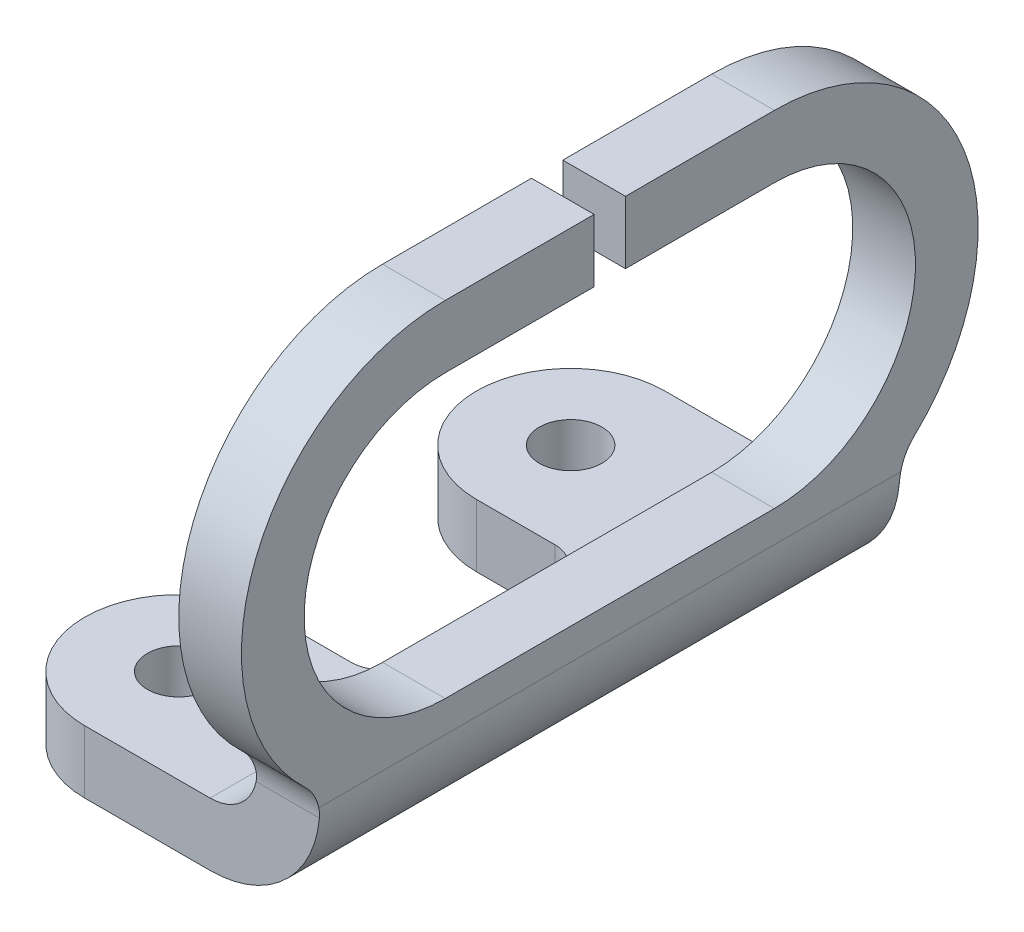
from build123d import *

# Parameters (mm, degrees)
SKETCH1_R           = 2
BOSS_EXTRUDE1_DEPTH = 4
SKETCH1_3_W         = 4
SKETCH1_3_H         = 56
BOSS_EXTRUDE2_DEPTH = 35
FILLET3_R           = 2
CUT_EXTRUDE2_DEPTH  = 10
SKETCH4_W           = 2
SKETCH4_H           = 8.349248205
CUT_EXTRUDE3_DEPTH  = 10
FILLET4_R           = 3
FILLET6_R           = 3
FILLET5_R           = 7


with BuildPart() as part:
    # Sketch1 → Boss-Extrude1 (new body)
    with BuildSketch(Plane(origin=(0, 0, 0), x_dir=(1, 0, 0), z_dir=(0, 1, 0))):
        with BuildLine():
            Line((33.647984737, 18.5), (22.647984737, 18.5))
            ThreePointArc((22.647984737, 18.5), (16.647984737, 12.5), (22.647984737, 6.5))
            Line((22.647984737, 6.5), (29.647984737, 6.5))
            Line((29.647984737, 6.5), (29.647984737, -6.5))
            Line((29.647984737, -6.5), (22.647984737, -6.5))
            ThreePointArc((22.647984737, -6.5), (16.647984737, -12.5), (22.647984737, -18.5))
            Line((22.647984737, -18.5), (33.647984737, -18.5))
            Line((33.647984737, -18.5), (33.647984737, 18.5))
        make_face()
        with Locations((22.647984737, 12.5)):
            Circle(SKETCH1_R, mode=Mode.SUBTRACT)
        with Locations((22.647984737, -12.5)):
            Circle(SKETCH1_R, mode=Mode.SUBTRACT)
    extrude(amount=BOSS_EXTRUDE1_DEPTH)

    # Sketch1_3 → Boss-Extrude2 (add)
    with BuildSketch(Plane(origin=(0, 0, 0), x_dir=(1, 0, 0), z_dir=(0, 1, 0))):
        with Locations((35.647984737, 0)):
            Rectangle(SKETCH1_3_W, SKETCH1_3_H)
    extrude(amount=BOSS_EXTRUDE2_DEPTH)

    # Fillet3
    fillet3_edges = [part.edges().sort_by_distance(p)[0] for p in [
        (29.647984737, 2, -6.5),
        (29.647984737, 2, 6.5),
    ]]
    fillet(fillet3_edges, radius=FILLET3_R)

    # Sketch3 → Cut-Extrude2 (cut)
    with BuildSketch(Plane(origin=(37.647984737, 0, 0), x_dir=(0, 0, -1), z_dir=(1, 0, 0))):
        with BuildLine():
            Line((-28, 0), (-18.5, 0))
            Line((-18.5, 0), (-18.5, 7.753049234))
            ThreePointArc((-18.5, 7.753049234), (-22.792484695, 22.230226947), (-10.5, 31))
            Line((-10.5, 31), (10.5, 31))
            ThreePointArc((10.5, 31), (22.792484695, 22.230226947), (18.5, 7.753049234))
            Line((18.5, 7.753049234), (18.5, 0))
            Line((18.5, 0), (28, 0))
            Line((28, 0), (28, 35))
            Line((28, 35), (-28, 35))
            Line((-28, 35), (-28, 0))
        make_face()
        with BuildLine():
            Line((-10.5, 9), (10.5, 9))
            ThreePointArc((10.5, 9), (19.5, 18), (10.5, 27))
            Line((10.5, 27), (-10.5, 27))
            ThreePointArc((-10.5, 27), (-19.5, 18), (-10.5, 9))
        make_face()
    extrude(amount=-CUT_EXTRUDE2_DEPTH, mode=Mode.SUBTRACT)

    # Sketch4 → Cut-Extrude3 (cut)
    with BuildSketch(Plane(origin=(37.647984737, 0, 0), x_dir=(0, 0, -1), z_dir=(1, 0, 0))):
        with Locations((0, 31.174624103)):
            Rectangle(SKETCH4_W, SKETCH4_H)
    extrude(amount=-CUT_EXTRUDE3_DEPTH, mode=Mode.SUBTRACT)

    # Fillet4
    fillet4_edges = [part.edges().sort_by_distance(p)[0] for p in [
        (35.647984737, 7.753049234, -18.5),
        (35.647984737, 7.753049234, 18.5),
    ]]
    fillet(fillet4_edges, radius=FILLET4_R)

    # Fillet6
    fillet6_edges = [part.edges().sort_by_distance(p)[0] for p in [
        (33.647984737, 4, 0),
    ]]
    fillet(fillet6_edges, radius=FILLET6_R)

    # Fillet5
    fillet5_edges = [part.edges().sort_by_distance(p)[0] for p in [
        (37.647984737, 0, 0),
    ]]
    fillet(fillet5_edges, radius=FILLET5_R)


solid = part.part
